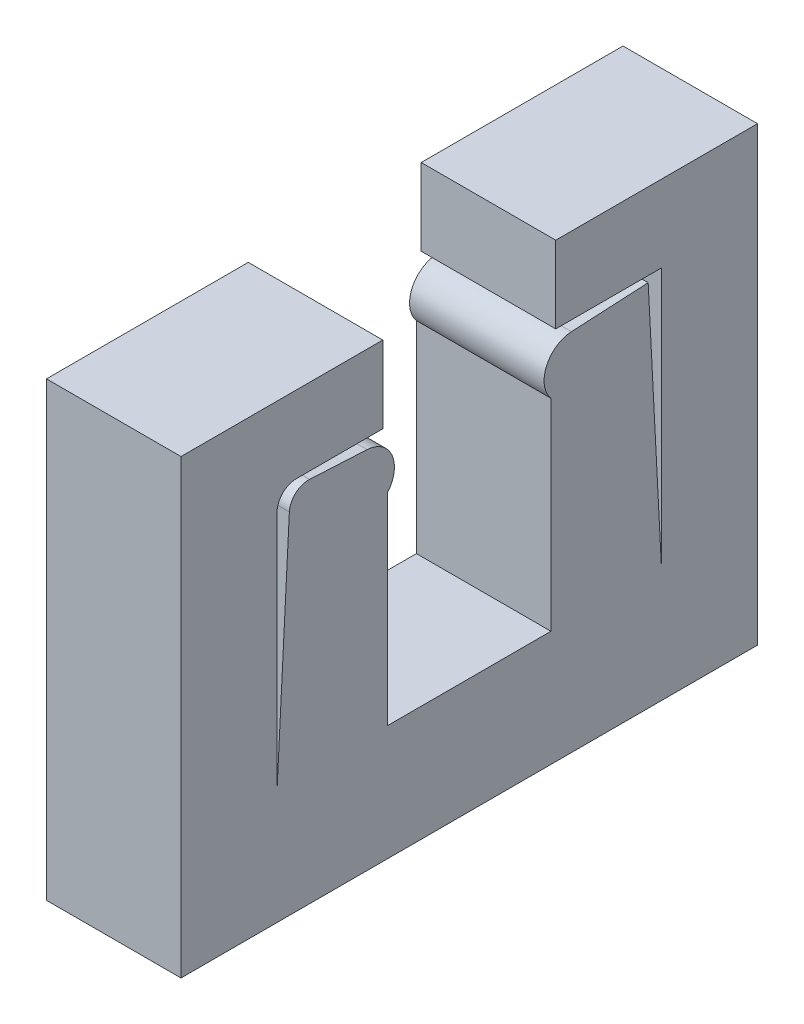
from build123d import *

# Parameters (mm, degrees)
BOSS_EXTRUDE2_DEPTH = 7
FILLET1_R           = 1
FILLET2_R           = 1


with BuildPart() as part:
    # Sketch4 → Boss-Extrude2 (new body)
    with BuildSketch(Plane(origin=(0, 0, 0), x_dir=(0, 0, -1), z_dir=(1, 0, 0))):
        with BuildLine():
            Line((-82.536856532, 31.771329741), (-81.846213718, 44.949579673))
            Line((-81.846213718, 44.949579673), (-77.851695579, 44.740235848))
            ThreePointArc((-77.851695579, 44.740235848), (-76.552846322, 43.836343889), (-76.786856532, 42.271329741))
            Line((-76.786856532, 42.271329741), (-76.786856532, 31.771329741))
            Line((-76.786856532, 31.771329741), (-72.536856532, 31.771329741))
            Line((-72.536856532, 31.771329741), (-72.536856532, 25.771329741))
            Line((-72.536856532, 25.771329741), (-87.536856532, 25.771329741))
            Line((-87.536856532, 25.771329741), (-87.536856532, 49.271329741))
            Line((-87.536856532, 49.271329741), (-77.036856532, 49.271329741))
            Line((-77.036856532, 49.271329741), (-77.036856532, 45.271329741))
            Line((-77.036856532, 45.271329741), (-82.536856532, 45.271329741))
            Line((-82.536856532, 45.271329741), (-82.536856532, 31.771329741))
        make_face()
    boss_extrude2 = extrude(amount=BOSS_EXTRUDE2_DEPTH)

    # Fillet1
    fillet1_edges = [part.edges().sort_by_distance(p)[0] for p in [
        (3.5, 44.949579673, 81.846213718),
    ]]
    fillet(fillet1_edges, radius=FILLET1_R)

    # Fillet2
    fillet2_edges = [part.edges().sort_by_distance(p)[0] for p in [
        (3.5, 45.271329741, 82.536856532),
    ]]
    fillet(fillet2_edges, radius=FILLET2_R)

    # Mirror2: Boss-Extrude2 across plane
    add(boss_extrude2.mirror(Plane(origin=(7, 31.771329741, 72.536856532), x_dir=(1, 0, 0), z_dir=(0, 0, 1))))


solid = part.part
